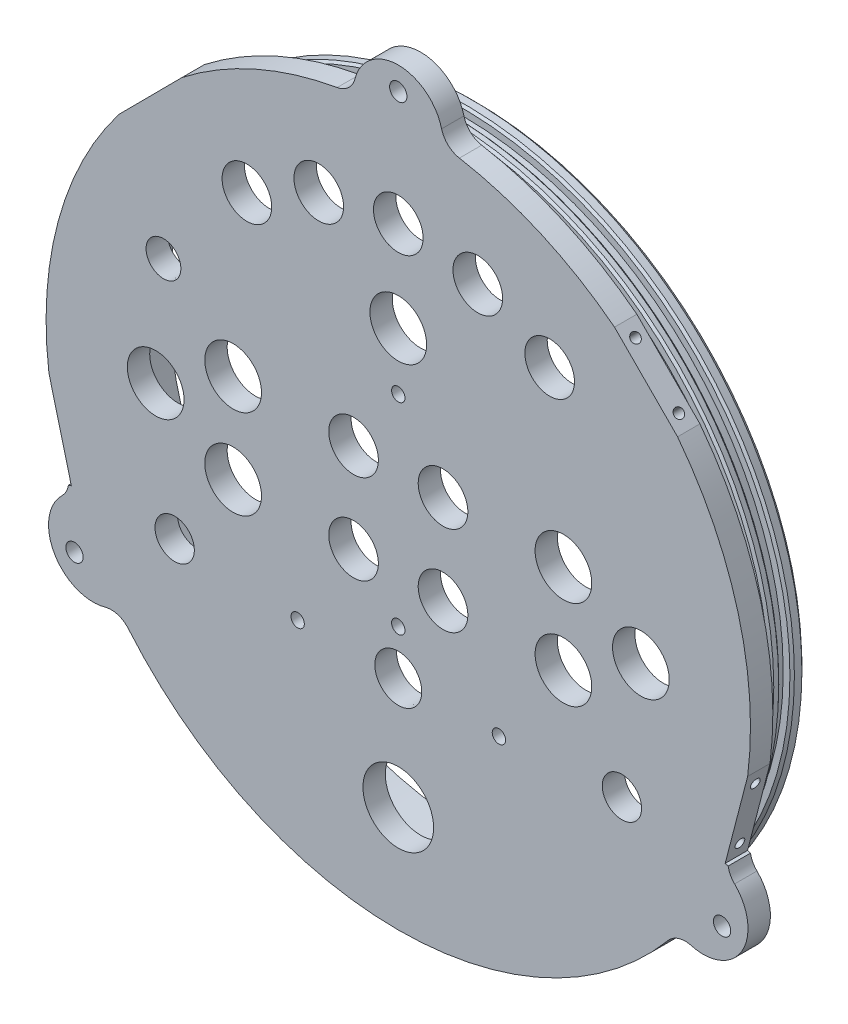
from build123d import *

# Parameters (mm, degrees)
SKETCH1_R                            = 100.0125
EXTRUDE1_DEPTH                       = 6.35
SKETCH2_R                            = 93.6625
EXTRUDE2_DEPTH                       = 15.875
SKETCH3_R                            = 87.3125
CUT_EXTRUDE1_DEPTH                   = 15.875
SKETCH4_W                            = 3.175
SKETCH4_H                            = 2.54
CHAMFER1_SIZE                        = 1.27
EXTRUDE3_DEPTH                       = 6.35
SKETCH5_R                            = 8.05
SKETCH5_R_2                          = 7.050000124
SKETCH5_R_3                          = 5.588
CUT_EXTRUDE2_DEPTH                   = 23.225
F_10_0_1935_DIAMETER_HOLE1_D         = 4.9149
F_10_0_1935_DIAMETER_HOLE1_DEPTH     = 330.2
F_10_0_1935_DIAMETER_HOLE1_TIP       = 1.476584928
CHAMFER2_SIZE                        = 0.635
SKETCH15_R                           = 10.033
CUT_EXTRUDE3_DEPTH                   = 23.225
SKETCH17_R                           = 7.05
SKETCH17_R_2                         = 8.05
CUT_EXTRUDE4_DEPTH                   = 23.225
F_6_CLEARANCE_HOLE1_D                = 3.7973
F_6_CLEARANCE_HOLE1_DEPTH            = 12.7
F_6_CLEARANCE_HOLE1_TIP              = 1.140824014
TAP_DRILL_FOR_6_TAP1_D               = 2.7051
TAP_DRILL_FOR_6_TAP1_DEPTH           = 3.302
TAP_DRILL_FOR_6_TAP1_TIP             = 0.81269403
FILLET1_R                            = 6.35
CUT_EXTRUDE5_DEPTH                   = 23.225
TAP_DRILL_FOR_6_TAP2_D               = 2.7051
TAP_DRILL_FOR_6_TAP2_DEPTH           = 9.525
TAP_DRILL_FOR_6_TAP2_TIP             = 0.81269403
TAP_DRILL_FOR_6_TAP2_ON_FACE_2_D     = 2.7051
TAP_DRILL_FOR_6_TAP2_ON_FACE_2_DEPTH = 9.525
TAP_DRILL_FOR_6_TAP2_ON_FACE_2_TIP   = 0.81269403
TAP_DRILL_FOR_6_TAP2_ON_FACE_3_D     = 2.7051
TAP_DRILL_FOR_6_TAP2_ON_FACE_3_DEPTH = 9.525
TAP_DRILL_FOR_6_TAP2_ON_FACE_3_TIP   = 0.81269403
TAP_DRILL_FOR_6_TAP2_ON_FACE_4_D     = 2.7051
TAP_DRILL_FOR_6_TAP2_ON_FACE_4_DEPTH = 9.525
TAP_DRILL_FOR_6_TAP2_ON_FACE_4_TIP   = 0.81269403
TAP_DRILL_FOR_6_TAP2_ON_FACE_5_D     = 2.7051
TAP_DRILL_FOR_6_TAP2_ON_FACE_5_DEPTH = 9.525
TAP_DRILL_FOR_6_TAP2_ON_FACE_5_TIP   = 0.81269403
TAP_DRILL_FOR_6_TAP2_ON_FACE_6_D     = 2.7051
TAP_DRILL_FOR_6_TAP2_ON_FACE_6_DEPTH = 9.525
TAP_DRILL_FOR_6_TAP2_ON_FACE_6_TIP   = 0.81269403
F_6_CLEARANCE_HOLE2_D                = 3.7973
F_6_CLEARANCE_HOLE2_DEPTH            = 6.35
F_6_CLEARANCE_HOLE2_TIP              = 1.140824014


with BuildPart() as part:
    # Sketch1 → Extrude1 (new body)
    with BuildSketch(Plane.XY):
        Circle(SKETCH1_R)
    extrude(amount=EXTRUDE1_DEPTH)

    # Sketch2 → Extrude2 (add)
    with BuildSketch(Plane(origin=(0, 0, 0), x_dir=(-1, 0, 0), z_dir=(0, 0, -1))):
        Circle(SKETCH2_R)
    extrude(amount=EXTRUDE2_DEPTH)

    # Sketch3 → Cut-Extrude1 (cut)
    with BuildSketch(Plane(origin=(0, 0, -15.875), x_dir=(-1, 0, 0), z_dir=(0, 0, -1))):
        Circle(SKETCH3_R)
    extrude(amount=-CUT_EXTRUDE1_DEPTH, mode=Mode.SUBTRACT)

    # Sketch4 → Cut-Revolve1 (revolve, cut)
    with BuildSketch(Plane(origin=(0, 0, 0), x_dir=(0, 0, -1), z_dir=(1, 0, 0))):
        with Locations((4.395911794, 92.3925)):
            Rectangle(SKETCH4_W, SKETCH4_H)
        with Locations((10.251990741, 92.3925)):
            Rectangle(SKETCH4_W, SKETCH4_H)
    revolve(axis=Axis((0, 0, 0), (0, 0, -1)), mode=Mode.SUBTRACT)

    # Chamfer1
    chamfer1_edges = [part.edges().sort_by_distance(p)[0] for p in [
        (93.6625, 0, -15.875),
    ]]
    chamfer(chamfer1_edges, length=CHAMFER1_SIZE)

    # Sketch8 → Extrude3 (add)
    with BuildSketch(Plane.XY.offset(6.35)):
        with BuildLine():
            ThreePointArc((-12.674375762, 99.206150794), (0, 112.7125), (12.674375762, 99.206150794))
            ThreePointArc((12.674375762, 99.206150794), (0, 100.0125), (-12.674375762, 99.206150794))
        make_face()
        with BuildLine():
            ThreePointArc((92.25223468, -38.62674401), (97.611888324, -56.35625), (79.577858918, -60.579406784))
            ThreePointArc((79.577858918, -60.579406784), (86.613365696, -50.00625), (92.25223468, -38.62674401))
        make_face()
        with BuildLine():
            ThreePointArc((-92.25223468, -38.62674401), (-97.611888324, -56.35625), (-79.577858918, -60.579406784))
            ThreePointArc((-79.577858918, -60.579406784), (-86.613365696, -50.00625), (-92.25223468, -38.62674401))
        make_face()
    extrude(amount=-EXTRUDE3_DEPTH)

    # Sketch5 → Cut-Extrude2 (cut, through all)
    with BuildSketch(Plane.XY.offset(6.35)):
        with Locations((0, 47.957267442)):
            Circle(SKETCH5_R)
        with Locations((0, 73.66)):
            Circle(SKETCH5_R_2)
        with Locations((-63.5, -35.56)):
            Circle(SKETCH5_R_3)
        with Locations((63.5, -35.56)):
            Circle(SKETCH5_R_3)
    extrude(amount=-CUT_EXTRUDE2_DEPTH, mode=Mode.SUBTRACT)

    # #10 (0.1935) Diameter Hole1
    with Locations(Plane(origin=(0, 106.172778556, 6.35), x_dir=(1, 0, 0), z_dir=(0, 0, 1))):
        with Locations((0, 0), (91.94832342, -159.259167834), (-91.94832342, -159.259167834)):
            Hole(F_10_0_1935_DIAMETER_HOLE1_D / 2, depth=F_10_0_1935_DIAMETER_HOLE1_DEPTH)
            with Locations((0, 0, -(F_10_0_1935_DIAMETER_HOLE1_DEPTH + F_10_0_1935_DIAMETER_HOLE1_TIP / 2))):  # 118° drill point
                Cone(0, F_10_0_1935_DIAMETER_HOLE1_D / 2, F_10_0_1935_DIAMETER_HOLE1_TIP, mode=Mode.SUBTRACT)

    # Chamfer2
    chamfer2_edges = [part.edges().sort_by_distance(p)[0] for p in [
        (93.6625, 0, -2.808411794),
        (93.6625, 0, -5.983411794),
        (93.6625, 0, -8.664490741),
        (93.6625, 0, -11.839490741),
    ]]
    chamfer(chamfer2_edges, length=CHAMFER2_SIZE)

    # Sketch15 → Cut-Extrude3 (cut, through all)
    with BuildSketch(Plane.XY.offset(6.35)):
        with Locations((0, -69.85)):
            Circle(SKETCH15_R)
    extrude(amount=-CUT_EXTRUDE3_DEPTH, mode=Mode.SUBTRACT)

    # Sketch17 → Cut-Extrude4 (cut, through all)
    with BuildSketch(Plane.XY.offset(6.35)):
        with Locations((-22.583106044, 70.112758621)):
            Circle(SKETCH17_R)
        with Locations((-42.9911448, 59.812683177)):
            Circle(SKETCH17_R)
        with Locations((-68.893058109, 0)):
            Circle(SKETCH17_R_2)
        with Locations((-46.896012853, -12.7)):
            Circle(SKETCH17_R_2)
        with Locations((-46.896012853, 12.7)):
            Circle(SKETCH17_R_2)
        with Locations((-12.7, 12.7)):
            Circle(SKETCH17_R)
        with Locations((-12.7, -12.7)):
            Circle(SKETCH17_R)
        with Locations((12.7, -12.7)):
            Circle(SKETCH17_R)
        with Locations((12.7, 12.7)):
            Circle(SKETCH17_R)
        with Locations((46.896012853, 12.7)):
            Circle(SKETCH17_R_2)
        with Locations((46.896012853, -12.7)):
            Circle(SKETCH17_R_2)
        with Locations((68.893058109, 0)):
            Circle(SKETCH17_R_2)
        with Locations((42.9911448, 59.812683177)):
            Circle(SKETCH17_R)
        with Locations((22.583106044, 70.112758621)):
            Circle(SKETCH17_R)
    extrude(amount=-CUT_EXTRUDE4_DEPTH, mode=Mode.SUBTRACT)

    # #6 Clearance Hole1
    with Locations(Plane(origin=(28.575, -38.1, 0), x_dir=(-1, 0, 0), z_dir=(0, 0, -1))):
        with Locations((0, 0), (57.15, 0)):
            Hole(F_6_CLEARANCE_HOLE1_D / 2, depth=F_6_CLEARANCE_HOLE1_DEPTH)
            with Locations((0, 0, -(F_6_CLEARANCE_HOLE1_DEPTH + F_6_CLEARANCE_HOLE1_TIP / 2))):  # 118° drill point
                Cone(0, F_6_CLEARANCE_HOLE1_D / 2, F_6_CLEARANCE_HOLE1_TIP, mode=Mode.SUBTRACT)

    # Tap Drill for #6 Tap1
    with Locations(Plane(origin=(34.925, 29.21, 0), x_dir=(-1, 0, 0), z_dir=(0, 0, -1))):
        with Locations((0, 0), (69.85, 0), (60.325, 0), (9.525, 0), (-9.525, -81.915), (79.375, -81.915)):
            Hole(TAP_DRILL_FOR_6_TAP1_D / 2, depth=TAP_DRILL_FOR_6_TAP1_DEPTH)
            with Locations((0, 0, -(TAP_DRILL_FOR_6_TAP1_DEPTH + TAP_DRILL_FOR_6_TAP1_TIP / 2))):  # 118° drill point
                Cone(0, TAP_DRILL_FOR_6_TAP1_D / 2, TAP_DRILL_FOR_6_TAP1_TIP, mode=Mode.SUBTRACT)

    # Sketch20 → 1/4 NPT Tapped Hole1 (revolve, cut)
    with BuildSketch(Plane(origin=(0, -38.1, 0), x_dir=(0, 1, 0), z_dir=(1, 0, 0))):
        Polygon((0, 0), (0, 20.360347279), (5.5626, 17.018), (5.5626, 9.906), (6.557984794, 9.906), (6.8545837, 0), align=None)
    revolve(axis=Axis((0, -38.1, -6.35), (0, 0, 1)), mode=Mode.SUBTRACT)

    # Sketch16 → 1/8 NPT Tapped Hole1 (revolve, cut)
    with BuildSketch(Plane(origin=(-66.675, 31.75, 0), x_dir=(0, 1, 0), z_dir=(1, 0, 0))):
        Polygon((0, 0), (0, 13.709468714), (4.2164, 11.176), (4.2164, 6.35), (4.936189396, 6.35), (5.1263169, 0), align=None)
    revolve(axis=Axis((-66.675, 31.75, -6.35), (0, 0, 1)), mode=Mode.SUBTRACT)

    # Fillet1
    fillet1_edges = [part.edges().sort_by_distance(p)[0] for p in [
        (12.674375762, 99.206150794, 3.175),
        (-12.674375762, 99.206150794, 3.175),
        (79.577858918, -60.579406784, 3.175),
        (92.25223468, -38.62674401, 3.175),
        (-92.25223468, -38.62674401, 3.175),
        (-79.577858918, -60.579406784, 3.175),
    ]]
    fillet(fillet1_edges, radius=FILLET1_R)

    # Sketch22 → Cut-Extrude5 (cut, through all)
    with BuildSketch(Plane.XY.offset(6.35)):
        Polygon((-79.302036552, 60.940029168), (-70.34752173, 69.945953012), (-61.393006907, 78.951876857), (-66.822744797, 84.350619868), (-84.731774442, 66.338772179), align=None)
        Polygon((-99.212091023, -12.627792806), (-96.021750906, -24.92054392), (-92.831410789, -37.213295033), (-99.212091023, -38.869274231), (-105.592771257, -14.283772004), align=None)
        Polygon((105.592771257, -14.283772004), (99.212091023, -12.627792806), (96.021750906, -24.92054392), (92.831410789, -37.213295033), (99.212091023, -38.869274231), align=None)
        Polygon((84.731774442, 66.338772179), (66.822744797, 84.350619868), (61.393006907, 78.951876857), (70.34752173, 69.945953012), (79.302036552, 60.940029168), align=None)
    extrude(amount=-CUT_EXTRUDE5_DEPTH, mode=Mode.SUBTRACT)

    # Tap Drill for #6 Tap2
    with Locations(Plane(origin=(-93.828392075, -33.37181031, 3.175), x_dir=(0.251207883, -0.967933159, 0), z_dir=(-0.967933159, -0.251207883, 0))):
        with Locations((0, 0)):
            Hole(TAP_DRILL_FOR_6_TAP2_D / 2, depth=TAP_DRILL_FOR_6_TAP2_DEPTH)
            with Locations((0, 0, -(TAP_DRILL_FOR_6_TAP2_DEPTH + TAP_DRILL_FOR_6_TAP2_TIP / 2))):  # 118° drill point
                Cone(0, TAP_DRILL_FOR_6_TAP2_D / 2, TAP_DRILL_FOR_6_TAP2_TIP, mode=Mode.SUBTRACT)

    # Tap Drill for #6 Tap2 on face 2
    with Locations(Plane(origin=(-98.215109736, -16.469277529, 3.175), x_dir=(0.251208031, -0.96793312, 0), z_dir=(-0.96793312, -0.251208031, 0))):
        with Locations((0, 0)):
            Hole(TAP_DRILL_FOR_6_TAP2_ON_FACE_2_D / 2, depth=TAP_DRILL_FOR_6_TAP2_ON_FACE_2_DEPTH)
            with Locations((0, 0, -(TAP_DRILL_FOR_6_TAP2_ON_FACE_2_DEPTH + TAP_DRILL_FOR_6_TAP2_ON_FACE_2_TIP / 2))):  # 118° drill point
                Cone(0, TAP_DRILL_FOR_6_TAP2_ON_FACE_2_D / 2, TAP_DRILL_FOR_6_TAP2_ON_FACE_2_TIP, mode=Mode.SUBTRACT)

    # Tap Drill for #6 Tap2 on face 3
    with Locations(Plane(origin=(-76.50375067, 63.754380369, 3.175), x_dir=(-0.705079885, -0.709127884, 0), z_dir=(-0.709127884, 0.705079885, 0))):
        with Locations((0, 0), (-17.4625, 0)):
            Hole(TAP_DRILL_FOR_6_TAP2_ON_FACE_3_D / 2, depth=TAP_DRILL_FOR_6_TAP2_ON_FACE_3_DEPTH)
            with Locations((0, 0, -(TAP_DRILL_FOR_6_TAP2_ON_FACE_3_DEPTH + TAP_DRILL_FOR_6_TAP2_ON_FACE_3_TIP / 2))):  # 118° drill point
                Cone(0, TAP_DRILL_FOR_6_TAP2_ON_FACE_3_D / 2, TAP_DRILL_FOR_6_TAP2_ON_FACE_3_TIP, mode=Mode.SUBTRACT)

    # Tap Drill for #6 Tap2 on face 4
    with Locations(Plane(origin=(64.191292789, 76.137525655, 3.175), x_dir=(-0.705079885, 0.709127884, 0), z_dir=(0.709127884, 0.705079885, 0))):
        with Locations((0, 0), (-17.4625, 0)):
            Hole(TAP_DRILL_FOR_6_TAP2_ON_FACE_4_D / 2, depth=TAP_DRILL_FOR_6_TAP2_ON_FACE_4_DEPTH)
            with Locations((0, 0, -(TAP_DRILL_FOR_6_TAP2_ON_FACE_4_DEPTH + TAP_DRILL_FOR_6_TAP2_ON_FACE_4_TIP / 2))):  # 118° drill point
                Cone(0, TAP_DRILL_FOR_6_TAP2_ON_FACE_4_D / 2, TAP_DRILL_FOR_6_TAP2_ON_FACE_4_TIP, mode=Mode.SUBTRACT)

    # Tap Drill for #6 Tap2 on face 5
    with Locations(Plane(origin=(98.215109736, -16.469277529, 3.175), x_dir=(0.251208031, 0.96793312, 0), z_dir=(0.96793312, -0.251208031, 0))):
        with Locations((0, 0)):
            Hole(TAP_DRILL_FOR_6_TAP2_ON_FACE_5_D / 2, depth=TAP_DRILL_FOR_6_TAP2_ON_FACE_5_DEPTH)
            with Locations((0, 0, -(TAP_DRILL_FOR_6_TAP2_ON_FACE_5_DEPTH + TAP_DRILL_FOR_6_TAP2_ON_FACE_5_TIP / 2))):  # 118° drill point
                Cone(0, TAP_DRILL_FOR_6_TAP2_ON_FACE_5_D / 2, TAP_DRILL_FOR_6_TAP2_ON_FACE_5_TIP, mode=Mode.SUBTRACT)

    # Tap Drill for #6 Tap2 on face 6
    with Locations(Plane(origin=(93.828392075, -33.37181031, 3.175), x_dir=(0.251208031, 0.96793312, 0), z_dir=(0.96793312, -0.251208031, 0))):
        with Locations((0, 0)):
            Hole(TAP_DRILL_FOR_6_TAP2_ON_FACE_6_D / 2, depth=TAP_DRILL_FOR_6_TAP2_ON_FACE_6_DEPTH)
            with Locations((0, 0, -(TAP_DRILL_FOR_6_TAP2_ON_FACE_6_DEPTH + TAP_DRILL_FOR_6_TAP2_ON_FACE_6_TIP / 2))):  # 118° drill point
                Cone(0, TAP_DRILL_FOR_6_TAP2_ON_FACE_6_D / 2, TAP_DRILL_FOR_6_TAP2_ON_FACE_6_TIP, mode=Mode.SUBTRACT)

    # #6 Clearance Hole2
    with Locations(Plane.XY.offset(6.35)):
        with Locations((0, 31.75), (0, -25.4)):
            Hole(F_6_CLEARANCE_HOLE2_D / 2, depth=F_6_CLEARANCE_HOLE2_DEPTH)
            with Locations((0, 0, -(F_6_CLEARANCE_HOLE2_DEPTH + F_6_CLEARANCE_HOLE2_TIP / 2))):  # 118° drill point
                Cone(0, F_6_CLEARANCE_HOLE2_D / 2, F_6_CLEARANCE_HOLE2_TIP, mode=Mode.SUBTRACT)


solid = part.part
